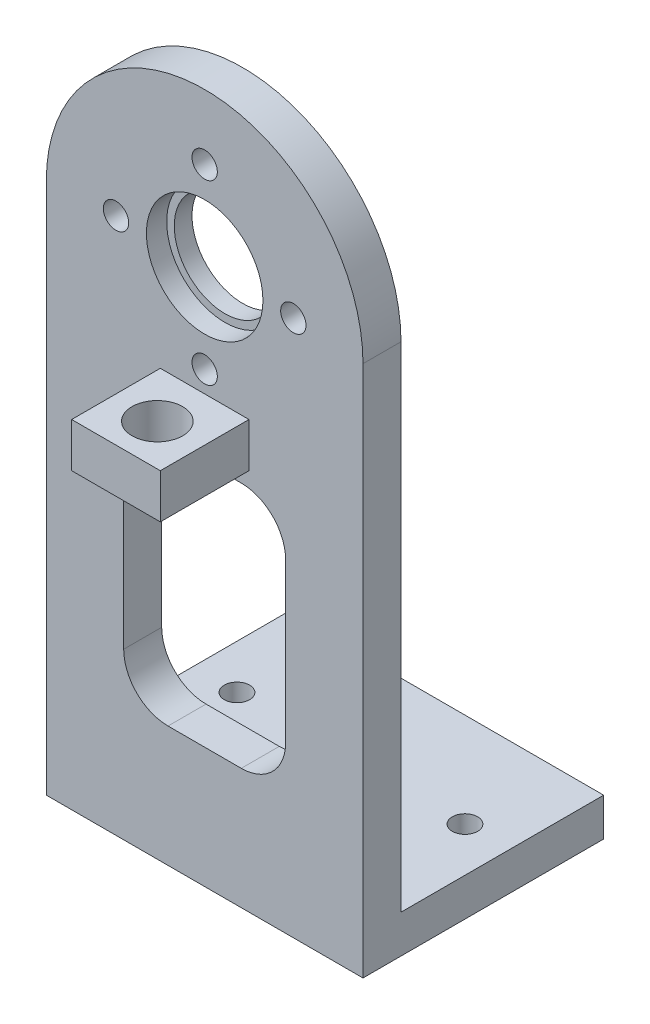
from build123d import *

# Parameters (mm, degrees)
SKETCH1_W           = 25
SKETCH1_H           = 38.558203604
SKETCH1_H_2         = 3.441796396
BOSS_EXTRUDE1_DEPTH = 3
SKETCH2_R           = 4
SKETCH2_R_2         = 1
CUT_EXTRUDE1_DEPTH  = 3
SKETCH4_R           = 4.6
CUT_EXTRUDE2_DEPTH  = 1.6
SKETCH5_W           = 25
SKETCH5_H           = 3
BOSS_EXTRUDE3_DEPTH = 19
SKETCH7_R           = 1
CUT_EXTRUDE4_DEPTH  = 4
SKETCH8_W           = 12.783853214
SKETCH8_H           = 19.5
CUT_EXTRUDE5_DEPTH  = 4
FILLET1_R           = 3.5
SKETCH9_W           = 7
SKETCH9_H           = 3.5
BOSS_EXTRUDE4_DEPTH = 7
SKETCH11_R          = 2
CUT_EXTRUDE6_DEPTH  = 10


with BuildPart() as part:
    # Sketch1 → Boss-Extrude1 (new body)
    with BuildSketch(Plane.XY):
        with Locations((0, 8.156339421)):
            Rectangle(SKETCH1_W, SKETCH1_H)
        with BuildLine():
            Line((-12.5, 27.435441223), (12.5, 27.435441223))
            ThreePointArc((12.5, 27.435441223), (0, 39.935441223), (-12.5, 27.435441223))
        make_face()
        with Locations((0, -12.843660579)):
            Rectangle(SKETCH1_W, SKETCH1_H_2)
    extrude(amount=BOSS_EXTRUDE1_DEPTH)

    # Sketch2 → Cut-Extrude1 (cut)
    with BuildSketch(Plane.XY.offset(3)):
        with Locations((0, 27.802049159)):
            Circle(SKETCH2_R)
        with Locations((0, 34.802049159)):
            Circle(SKETCH2_R_2)
        with Locations((7, 27.802049159)):
            Circle(SKETCH2_R_2)
        with Locations((0, 20.802049159)):
            Circle(SKETCH2_R_2)
        with Locations((-7, 27.802049159)):
            Circle(SKETCH2_R_2)
    extrude(amount=-CUT_EXTRUDE1_DEPTH, mode=Mode.SUBTRACT)

    # Sketch4 → Cut-Extrude2 (cut)
    with BuildSketch(Plane.XY.offset(3)):
        with Locations((0, 27.802049159)):
            Circle(SKETCH4_R)
    extrude(amount=-CUT_EXTRUDE2_DEPTH, mode=Mode.SUBTRACT)

    # Sketch5 → Boss-Extrude3 (add)
    with BuildSketch(Plane.XY.offset(3)):
        with Locations((0, -13.064558777)):
            Rectangle(SKETCH5_W, SKETCH5_H)
    extrude(amount=-BOSS_EXTRUDE3_DEPTH)

    # Sketch7 → Cut-Extrude4 (cut)
    with BuildSketch(Plane(origin=(0, -11.564558777, 0), x_dir=(1, 0, 0), z_dir=(0, 1, 0))):
        with Locations((9, 8.55)):
            Circle(SKETCH7_R)
        with Locations((-9, 8.55)):
            Circle(SKETCH7_R)
    extrude(amount=-CUT_EXTRUDE4_DEPTH, mode=Mode.SUBTRACT)

    # Sketch8 → Cut-Extrude5 (cut)
    with BuildSketch(Plane.XY.offset(3)):
        with Locations((0, 4.716978639)):
            Rectangle(SKETCH8_W, SKETCH8_H)
    extrude(amount=-CUT_EXTRUDE5_DEPTH, mode=Mode.SUBTRACT)

    # Fillet1
    fillet1_edges = [part.edges().sort_by_distance(p)[0] for p in [
        (6.391926607, 14.466978639, 1.5),
        (6.391926607, -5.033021361, 1.5),
        (-6.391926607, -5.033021361, 1.5),
        (-6.391926607, 14.466978639, 1.5),
    ]]
    fillet(fillet1_edges, radius=FILLET1_R)

    # Sketch9 → Boss-Extrude4 (add)
    with BuildSketch(Plane.XY.offset(3)):
        with Locations((0, 17.369326997)):
            Rectangle(SKETCH9_W, SKETCH9_H)
    extrude(amount=BOSS_EXTRUDE4_DEPTH)

    # Sketch11 → Cut-Extrude6 (cut)
    with BuildSketch(Plane(origin=(0, 19.119326997, 0), x_dir=(1, 0, 0), z_dir=(0, 1, 0))):
        with Locations((0, -6.735728941)):
            Circle(SKETCH11_R)
    extrude(amount=-CUT_EXTRUDE6_DEPTH, mode=Mode.SUBTRACT)


solid = part.part
